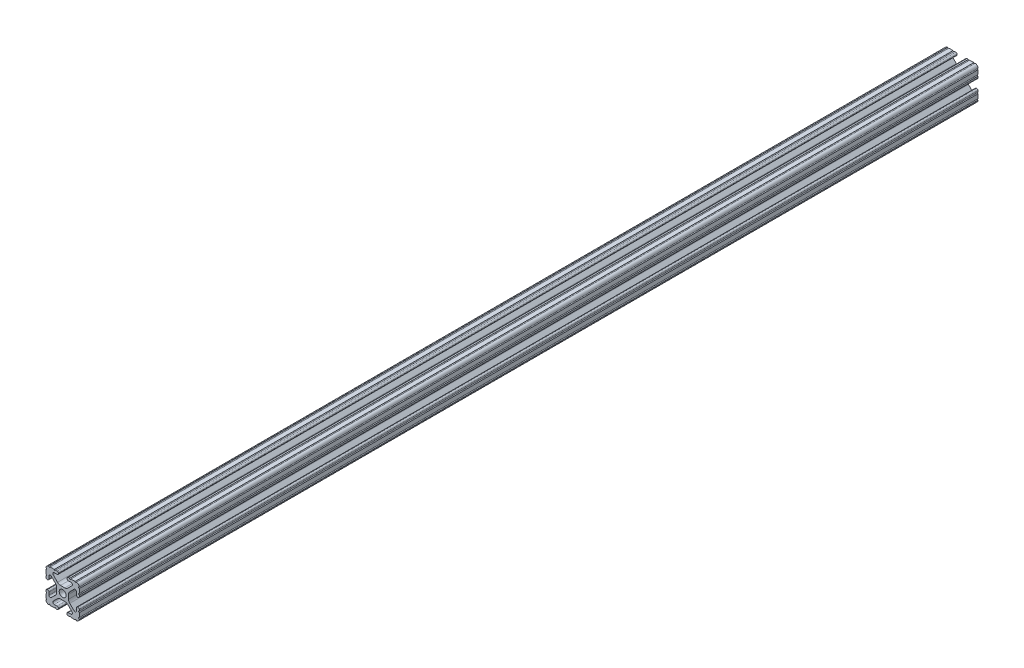
from build123d import *

# Parameters (mm, degrees)
SKETCH1_R               = 2.6035
BOSS_EXTRUDE1_DEPTH     = 342.9
SKETCH2_R               = 3.175
CUT_EXTRUDE1_DEPTH      = 9.1915
CUT_EXTRUDE1_DEPTH_BACK = 18.2085


with BuildPart() as part:
    # Sketch1 → Boss-Extrude1 (new body, symmetric)
    with BuildSketch(Plane.XY):
        with BuildLine():
            Line((-7.179650497, -8.645192506), (-3.952270251, -5.423690499))
            ThreePointArc((-3.952270251, -5.423690499), (-2.922936451, -4.736929036), (-1.709253557, -4.4958))
            Line((-1.709253557, -4.4958), (1.709253557, -4.4958))
            ThreePointArc((1.709253557, -4.4958), (2.922936451, -4.736929036), (3.952270251, -5.423690499))
            Line((3.952270251, -5.423690499), (7.179650497, -8.645192506))
            ThreePointArc((7.179650497, -8.645192506), (7.41473083, -9.822813117), (6.416408329, -10.4902))
            Line((6.416408329, -10.4902), (4.287512407, -10.4902))
            ThreePointArc((4.287512407, -10.4902), (3.54574862, -10.79744862), (3.2385, -11.539212407))
            Line((3.2385, -11.539212407), (3.2385, -11.650987593))
            ThreePointArc((3.2385, -11.650987593), (3.54574862, -12.39275138), (4.287512407, -12.7))
            Line((4.287512407, -12.7), (5.317126718, -12.7))
            ThreePointArc((5.317126718, -12.7), (5.825126718, -12.192), (6.333126718, -12.7))
            Line((6.333126718, -12.7), (9.550443118, -12.7))
            ThreePointArc((9.550443118, -12.7), (10.058366869, -12.192000006), (10.566443095, -12.699847501))
            ThreePointArc((10.566443095, -12.699847501), (12.082537762, -12.08250727), (12.699846982, -10.566399977))
            ThreePointArc((12.699846982, -10.566399977), (12.192000006, -10.058323491), (12.7, -9.5504))
            Line((12.7, -9.5504), (12.7, -6.3330836))
            ThreePointArc((12.7, -6.3330836), (12.192, -5.8250836), (12.7, -5.3170836))
            Line((12.7, -5.3170836), (12.7, -4.287469289))
            ThreePointArc((12.7, -4.287469289), (12.39275138, -3.545705502), (11.650987593, -3.238456882))
            Line((11.650987593, -3.238456882), (11.539212407, -3.238456882))
            ThreePointArc((11.539212407, -3.238456882), (10.79744862, -3.545705502), (10.4902, -4.287469289))
            Line((10.4902, -4.287469289), (10.4902, -6.402089023))
            ThreePointArc((10.4902, -6.402089023), (9.856505071, -7.351067942), (8.737131347, -7.129408934))
            Line((8.737131347, -7.129408934), (5.441005833, -3.840816462))
            ThreePointArc((5.441005833, -3.840816462), (4.750877967, -2.809883091), (4.5085, -1.593185507))
            Line((4.5085, -1.593185507), (4.5085, 1.593185507))
            ThreePointArc((4.5085, 1.593185507), (4.750877967, 2.809883091), (5.441005833, 3.840816462))
            Line((5.441005833, 3.840816462), (8.737131347, 7.129408934))
            ThreePointArc((8.737131347, 7.129408934), (9.856505071, 7.351067942), (10.4902, 6.402089023))
            Line((10.4902, 6.402089023), (10.4902, 4.287469289))
            ThreePointArc((10.4902, 4.287469289), (10.79744862, 3.545705502), (11.539212407, 3.238456882))
            Line((11.539212407, 3.238456882), (11.650987593, 3.238456882))
            ThreePointArc((11.650987593, 3.238456882), (12.39275138, 3.545705502), (12.7, 4.287469289))
            Line((12.7, 4.287469289), (12.7, 5.3170836))
            ThreePointArc((12.7, 5.3170836), (12.192, 5.8250836), (12.7, 6.3330836))
            Line((12.7, 6.3330836), (12.7, 9.5504))
            ThreePointArc((12.7, 9.5504), (12.192000006, 10.058323491), (12.699846982, 10.566399977))
            ThreePointArc((12.699846982, 10.566399977), (12.082537762, 12.08250727), (10.566443095, 12.699847501))
            ThreePointArc((10.566443095, 12.699847501), (10.058366869, 12.192000006), (9.550443118, 12.7))
            Line((9.550443118, 12.7), (6.333126718, 12.7))
            ThreePointArc((6.333126718, 12.7), (5.825126718, 12.192), (5.317126718, 12.7))
            Line((5.317126718, 12.7), (4.287512407, 12.7))
            ThreePointArc((4.287512407, 12.7), (3.54574862, 12.39275138), (3.2385, 11.650987593))
            Line((3.2385, 11.650987593), (3.2385, 11.539212407))
            ThreePointArc((3.2385, 11.539212407), (3.54574862, 10.79744862), (4.287512407, 10.4902))
            Line((4.287512407, 10.4902), (6.476788598, 10.4902))
            ThreePointArc((6.476788598, 10.4902), (7.432222385, 9.85140422), (7.207036008, 8.724370562))
            Line((7.207036008, 8.724370562), (3.898272566, 5.423169045))
            ThreePointArc((3.898272566, 5.423169045), (2.869120213, 4.736787962), (1.655778399, 4.4958))
            Line((1.655778399, 4.4958), (-1.655778399, 4.4958))
            ThreePointArc((-1.655778399, 4.4958), (-2.869120213, 4.736787962), (-3.898272566, 5.423169045))
            Line((-3.898272566, 5.423169045), (-7.207036008, 8.724370562))
            ThreePointArc((-7.207036008, 8.724370562), (-7.432222385, 9.85140422), (-6.476788598, 10.4902))
            Line((-6.476788598, 10.4902), (-4.287512407, 10.4902))
            ThreePointArc((-4.287512407, 10.4902), (-3.54574862, 10.79744862), (-3.2385, 11.539212407))
            Line((-3.2385, 11.539212407), (-3.2385, 11.650987593))
            ThreePointArc((-3.2385, 11.650987593), (-3.54574862, 12.39275138), (-4.287512407, 12.7))
            Line((-4.287512407, 12.7), (-5.317126718, 12.7))
            ThreePointArc((-5.317126718, 12.7), (-5.825126718, 12.192), (-6.333126718, 12.7))
            Line((-6.333126718, 12.7), (-9.550443118, 12.7))
            ThreePointArc((-9.550443118, 12.7), (-10.058366869, 12.192000006), (-10.566443095, 12.699847501))
            ThreePointArc((-10.566443095, 12.699847501), (-12.082537762, 12.08250727), (-12.699846982, 10.566399977))
            ThreePointArc((-12.699846982, 10.566399977), (-12.192000006, 10.058323491), (-12.7, 9.5504))
            Line((-12.7, 9.5504), (-12.7, 6.3330836))
            ThreePointArc((-12.7, 6.3330836), (-12.192, 5.8250836), (-12.7, 5.3170836))
            Line((-12.7, 5.3170836), (-12.7, 4.287469289))
            ThreePointArc((-12.7, 4.287469289), (-12.39275138, 3.545705502), (-11.650987593, 3.238456882))
            Line((-11.650987593, 3.238456882), (-11.539212407, 3.238456882))
            ThreePointArc((-11.539212407, 3.238456882), (-10.79744862, 3.545705502), (-10.4902, 4.287469289))
            Line((-10.4902, 4.287469289), (-10.4902, 6.402089023))
            ThreePointArc((-10.4902, 6.402089023), (-9.856505071, 7.351067942), (-8.737131347, 7.129408934))
            Line((-8.737131347, 7.129408934), (-5.441005833, 3.840816462))
            ThreePointArc((-5.441005833, 3.840816462), (-4.750877967, 2.809883091), (-4.5085, 1.593185507))
            Line((-4.5085, 1.593185507), (-4.5085, -1.593185507))
            ThreePointArc((-4.5085, -1.593185507), (-4.750877967, -2.809883091), (-5.441005833, -3.840816462))
            Line((-5.441005833, -3.840816462), (-8.737131347, -7.129408934))
            ThreePointArc((-8.737131347, -7.129408934), (-9.856505071, -7.351067942), (-10.4902, -6.402089023))
            Line((-10.4902, -6.402089023), (-10.4902, -4.287469289))
            ThreePointArc((-10.4902, -4.287469289), (-10.79744862, -3.545705502), (-11.539212407, -3.238456882))
            Line((-11.539212407, -3.238456882), (-11.650987593, -3.238456882))
            ThreePointArc((-11.650987593, -3.238456882), (-12.39275138, -3.545705502), (-12.7, -4.287469289))
            Line((-12.7, -4.287469289), (-12.7, -5.3170836))
            ThreePointArc((-12.7, -5.3170836), (-12.192, -5.8250836), (-12.7, -6.3330836))
            Line((-12.7, -6.3330836), (-12.7, -9.5504))
            ThreePointArc((-12.7, -9.5504), (-12.192000006, -10.058323491), (-12.699846982, -10.566399977))
            ThreePointArc((-12.699846982, -10.566399977), (-12.082537762, -12.08250727), (-10.566443095, -12.699847501))
            ThreePointArc((-10.566443095, -12.699847501), (-10.058366869, -12.192000006), (-9.550443118, -12.7))
            Line((-9.550443118, -12.7), (-6.333126718, -12.7))
            ThreePointArc((-6.333126718, -12.7), (-5.825126718, -12.192), (-5.317126718, -12.7))
            Line((-5.317126718, -12.7), (-4.287512407, -12.7))
            ThreePointArc((-4.287512407, -12.7), (-3.54574862, -12.39275138), (-3.2385, -11.650987593))
            Line((-3.2385, -11.650987593), (-3.2385, -11.539212407))
            ThreePointArc((-3.2385, -11.539212407), (-3.54574862, -10.79744862), (-4.287512407, -10.4902))
            Line((-4.287512407, -10.4902), (-6.416408329, -10.4902))
            ThreePointArc((-6.416408329, -10.4902), (-7.41473083, -9.822813117), (-7.179650497, -8.645192506))
        make_face()
        Circle(SKETCH1_R, mode=Mode.SUBTRACT)
    extrude(amount=BOSS_EXTRUDE1_DEPTH, both=True)

    # Sketch2 → Cut-Extrude1 (cut, two sides)
    with BuildSketch(Plane(origin=(4.5085, 0, 0), x_dir=(0, 0, -1), z_dir=(1, 0, 0))) as cut_extrude1_sk:
        with Locations((-225.42, 0)):
            Circle(SKETCH2_R)
        with Locations((225.42, 0)):
            Circle(SKETCH2_R)
        with Locations((38.1, 0)):
            Circle(SKETCH2_R)
        with Locations((-38.1, 0)):
            Circle(SKETCH2_R)
    extrude(amount=CUT_EXTRUDE1_DEPTH, mode=Mode.SUBTRACT)
    extrude(cut_extrude1_sk.sketch, amount=-CUT_EXTRUDE1_DEPTH_BACK, mode=Mode.SUBTRACT)


solid = part.part
